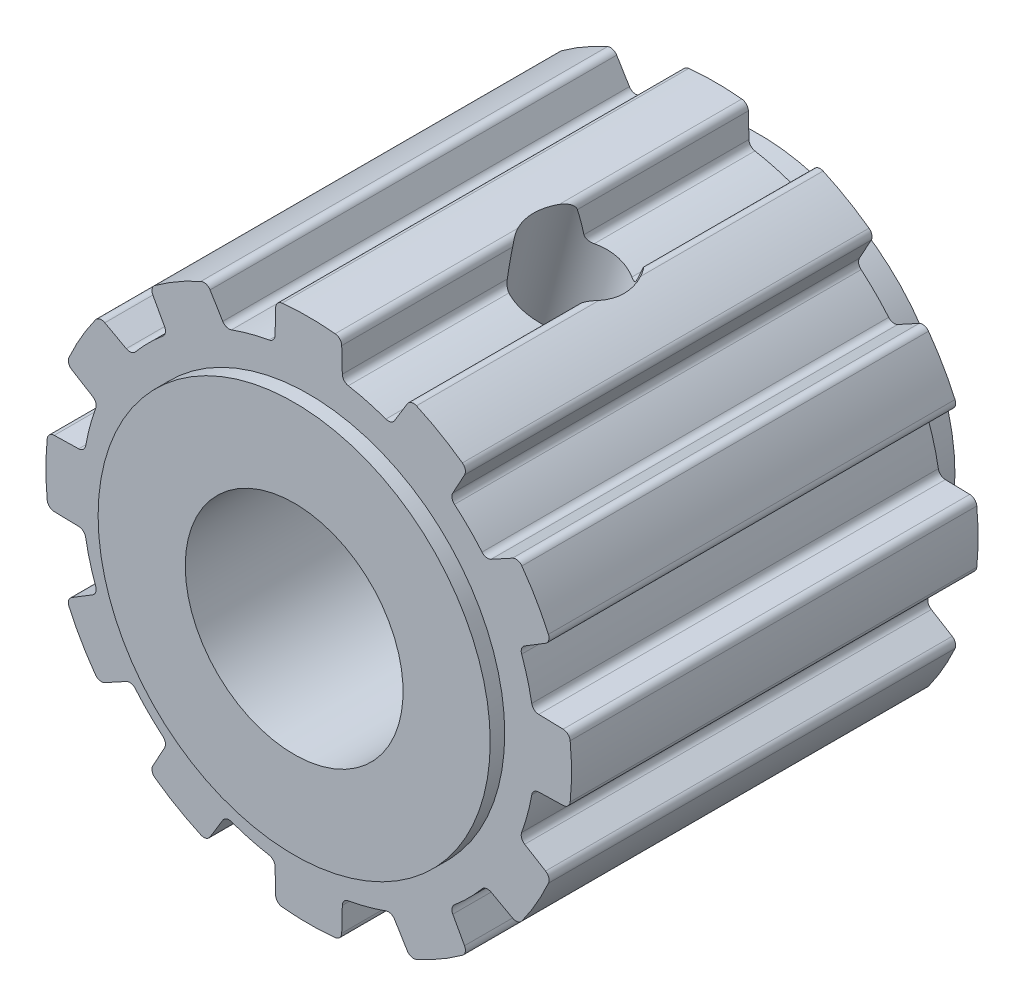
from build123d import *

# Parameters (mm, degrees)
BASE_EXTRUSION_DEPTH    = 28
ENL_V_MAT_EXTRU_1_DEPTH = 29
ESQUISSE3_R             = 13.5
BOSS_EXTRU_1_DEPTH      = 1
ESQUISSE4_R             = 13.5
BOSS_EXTRU_2_DEPTH      = 3
ESQUISSE5_R             = 10
BOSS_EXTRU_3_DEPTH      = 2
ESQUISSE6_R             = 7.5
ENL_V_MAT_EXTRU_2_DEPTH = 35
ESQUISSE7_R             = 3.23
ENL_V_MAT_EXTRU_3_DEPTH = 23.166159166


with BuildPart() as part:
    # Esquisse1 → Base-Extrusion (new body)
    with BuildSketch(Plane.XY):
        with BuildLine():
            Line((0, 0), (4.037212989, 15.067083998))
            ThreePointArc((4.037212989, 15.067083998), (3.385435719, 15.226783439), (2.727392851, 15.358301897))
            ThreePointArc((2.727392851, 15.358301897), (2.435520148, 15.524817781), (2.314964099, 15.838479149))
            Line((2.314964099, 15.838479149), (2.274165434, 17.521040915))
            ThreePointArc((2.274165434, 17.521040915), (2.141169678, 17.84864938), (1.824722991, 18.006372782))
            ThreePointArc((1.824722991, 18.006372782), (0.913525943, 18.075523371), (0, 18.098593171))
            Line((0, 18.098593171), (0, 0))
        make_face()
    extrude(amount=BASE_EXTRUSION_DEPTH)


with BuildPart() as body_2:
    # Bossage-Symétrie1: mirrored copy
    add(part.part.mirror(Plane(origin=(0, 9.049296586, 14), x_dir=(0, 0, 1), z_dir=(-1, 0, 0))))

    # Bossage-Sym_trie2 2: body 2 across face


with BuildPart() as part_1:
    add(part.part)

    # Bossage-Symétrie2: part across face
    add(part.part.mirror(Plane(origin=(2.018606495, 7.533541999, 14), x_dir=(0, 0, 1), z_dir=(0.965925826, -0.258819045, 0))))

    # Bossage-Symétrie3: part across face


with BuildPart() as body_2_1:
    add(body_2.part)
    add(body_2.part.mirror(Plane(origin=(2.018606495, 7.533541999, 14), x_dir=(0, 0, 1), z_dir=(0.965925826, -0.258819045, 0))))

    # Bossage-Sym_trie3 2: body 2 across face


with BuildPart() as part_2:
    add(part_1.part)
    add(part_1.part.mirror(Plane(origin=(5.514935504, 5.514935504, 14), x_dir=(0, 0, 1), z_dir=(0.707106781, -0.707106781, 0))))

    # Bossage-Symétrie4: part across face


with BuildPart() as body_2_2:
    add(body_2_1.part)
    add(body_2_1.part.mirror(Plane(origin=(5.514935504, 5.514935504, 14), x_dir=(0, 0, 1), z_dir=(0.707106781, -0.707106781, 0))))

    # Bossage-Sym_trie4 2: body 2 across face


with BuildPart() as part_3:
    add(part_2.part)
    add(part_2.part.mirror(Plane(origin=(7.533541999, -2.018606495, 14), x_dir=(0, 0, 1), z_dir=(-0.258819045, -0.965925826, 0))))


with BuildPart() as body_2_3:
    add(body_2_2.part)
    add(body_2_2.part.mirror(Plane(origin=(7.533541999, -2.018606495, 14), x_dir=(0, 0, 1), z_dir=(-0.258819045, -0.965925826, 0))))


with BuildPart() as enl_v_mat_extru_1_tool:
    # Esquisse2 → Enlèv. mat.-Extru.1 (new body, through all)
    with BuildSketch(Plane.XY.offset(28)):
        Polygon((0, 109.037962428), (0, 18.098593171), (0, -18.098593171), (0, -109.037962428), (-181.878738514, -109.037962428), (-181.878738514, 109.037962428), align=None)
    extrude(amount=-ENL_V_MAT_EXTRU_1_DEPTH)


with BuildPart() as part_4:
    add(part_3.part)

    # Enlèv. mat.-Extru.1: cut by enl_v_mat_extru_1_tool
    add(enl_v_mat_extru_1_tool.part, mode=Mode.SUBTRACT)

    # Bossage-Symétrie5: part across face


with BuildPart() as body_2_4:
    add(body_2_3.part)

    # Enlèv. mat.-Extru.1: cut by enl_v_mat_extru_1_tool
    add(enl_v_mat_extru_1_tool.part, mode=Mode.SUBTRACT)

    # Bossage-Sym_trie5 2: body 2 across face


with BuildPart() as part_5:
    add(part_4.part)
    add(part_4.part.mirror(Plane(origin=(1e-09, -9.049296586, 14), x_dir=(0, 0, 1), z_dir=(-1, 0, 0))))



with BuildPart() as body_2_5:
    add(body_2_4.part)
    add(body_2_4.part.mirror(Plane(origin=(1e-09, -9.049296586, 14), x_dir=(0, 0, 1), z_dir=(-1, 0, 0))))


with BuildPart() as part_6:
    add(part_5.part)

    add(body_2_5.part)  # Boss.-Extru.1 merges body 2
    # Esquisse3 → Boss.-Extru.1 (add)
    with BuildSketch(Plane.XY.offset(28)):
        Circle(ESQUISSE3_R)
    extrude(amount=BOSS_EXTRU_1_DEPTH)

    # Esquisse4 → Boss.-Extru.2 (add)
    with BuildSketch(Plane(origin=(0, 0, 0), x_dir=(-1, 0, 0), z_dir=(0, 0, -1))):
        Circle(ESQUISSE4_R)
    extrude(amount=BOSS_EXTRU_2_DEPTH)

    # Esquisse5 → Boss.-Extru.3 (add)
    with BuildSketch(Plane(origin=(0, 0, -3), x_dir=(-1, 0, 0), z_dir=(0, 0, -1))):
        Circle(ESQUISSE5_R)
    extrude(amount=BOSS_EXTRU_3_DEPTH)

    # Esquisse6 → Enlèv. mat.-Extru.2 (cut, through all)
    with BuildSketch(Plane(origin=(0, 0, -5), x_dir=(-1, 0, 0), z_dir=(0, 0, -1))):
        Circle(ESQUISSE6_R)
    extrude(amount=-ENL_V_MAT_EXTRU_2_DEPTH, mode=Mode.SUBTRACT)

    # Esquisse7 → Enlèv. mat.-Extru.3 (cut, through all)
    with BuildSketch(Plane(origin=(0, 0, 0), x_dir=(-0.965925826, 0.258819045, 0), z_dir=(0.258819045, 0.965925826, 0))):
        with Locations((0, 14)):
            Circle(ESQUISSE7_R)
    extrude(amount=ENL_V_MAT_EXTRU_3_DEPTH, mode=Mode.SUBTRACT)


solid = part_6.part
